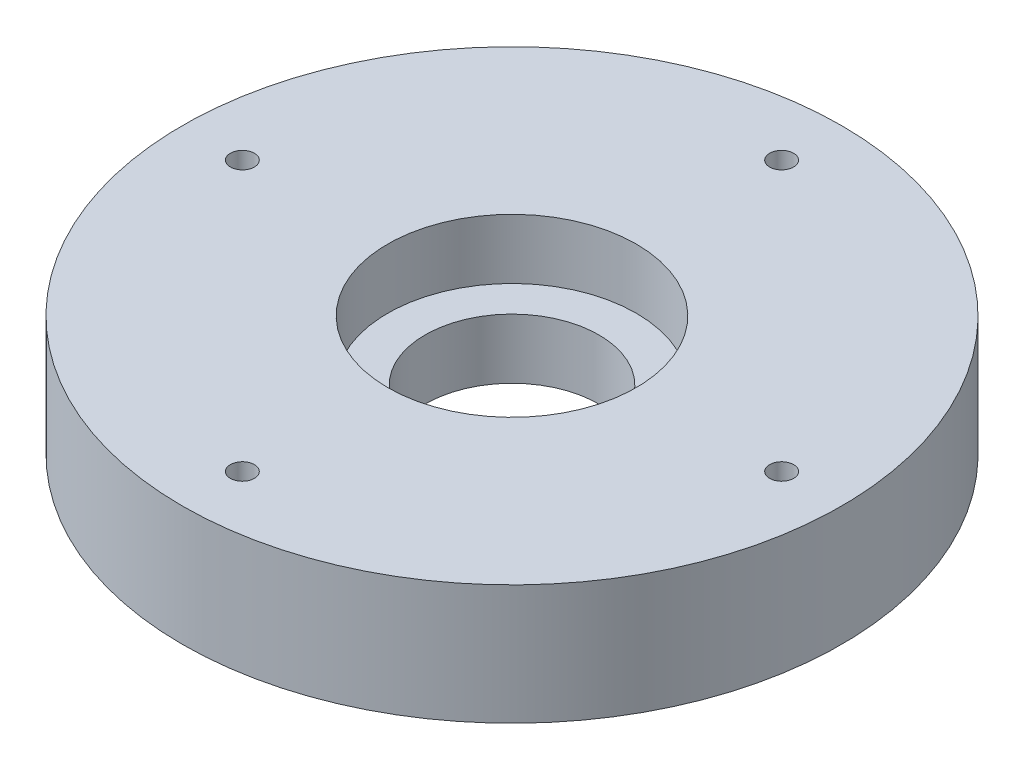
from build123d import *

# Parameters (mm, degrees)
SKETCH1_R           = 55
SKETCH1_R_2         = 14.5
BOSS_EXTRUDE1_DEPTH = 20
SKETCH2_R           = 20.75
CUT_EXTRUDE1_DEPTH  = 10
SKETCH4_R           = 2
CUT_EXTRUDE2_DEPTH  = 20
SKETCH6_R           = 5
CUT_EXTRUDE3_DEPTH  = 5


with BuildPart() as part:
    # Sketch1 → Boss-Extrude1 (new body)
    with BuildSketch(Plane(origin=(0, 0, 0), x_dir=(1, 0, 0), z_dir=(0, 1, 0))):
        Circle(SKETCH1_R)
        Circle(SKETCH1_R_2, mode=Mode.SUBTRACT)
    extrude(amount=BOSS_EXTRUDE1_DEPTH)

    # Sketch2 → Cut-Extrude1 (cut)
    with BuildSketch(Plane(origin=(0, 20, 0), x_dir=(1, 0, 0), z_dir=(0, 1, 0))):
        Circle(SKETCH2_R)
    extrude(amount=-CUT_EXTRUDE1_DEPTH, mode=Mode.SUBTRACT)

    # Sketch4 → Cut-Extrude2 (cut)
    with BuildSketch(Plane(origin=(0, 20, 0), x_dir=(1, 0, 0), z_dir=(0, 1, 0))):
        with Locations((0, 45)):
            Circle(SKETCH4_R)
        with Locations((45, 0)):
            Circle(SKETCH4_R)
        with Locations((0, -45)):
            Circle(SKETCH4_R)
        with Locations((-45, 0)):
            Circle(SKETCH4_R)
    extrude(amount=-CUT_EXTRUDE2_DEPTH, mode=Mode.SUBTRACT)

    # Sketch6 → Cut-Extrude3 (cut)
    with BuildSketch(Plane.XZ):
        with Locations((0, 45)):
            Circle(SKETCH6_R)
        with Locations((45, 0)):
            Circle(SKETCH6_R)
        with Locations((0, -45)):
            Circle(SKETCH6_R)
        with Locations((-45, 0)):
            Circle(SKETCH6_R)
    extrude(amount=-CUT_EXTRUDE3_DEPTH, mode=Mode.SUBTRACT)


solid = part.part
